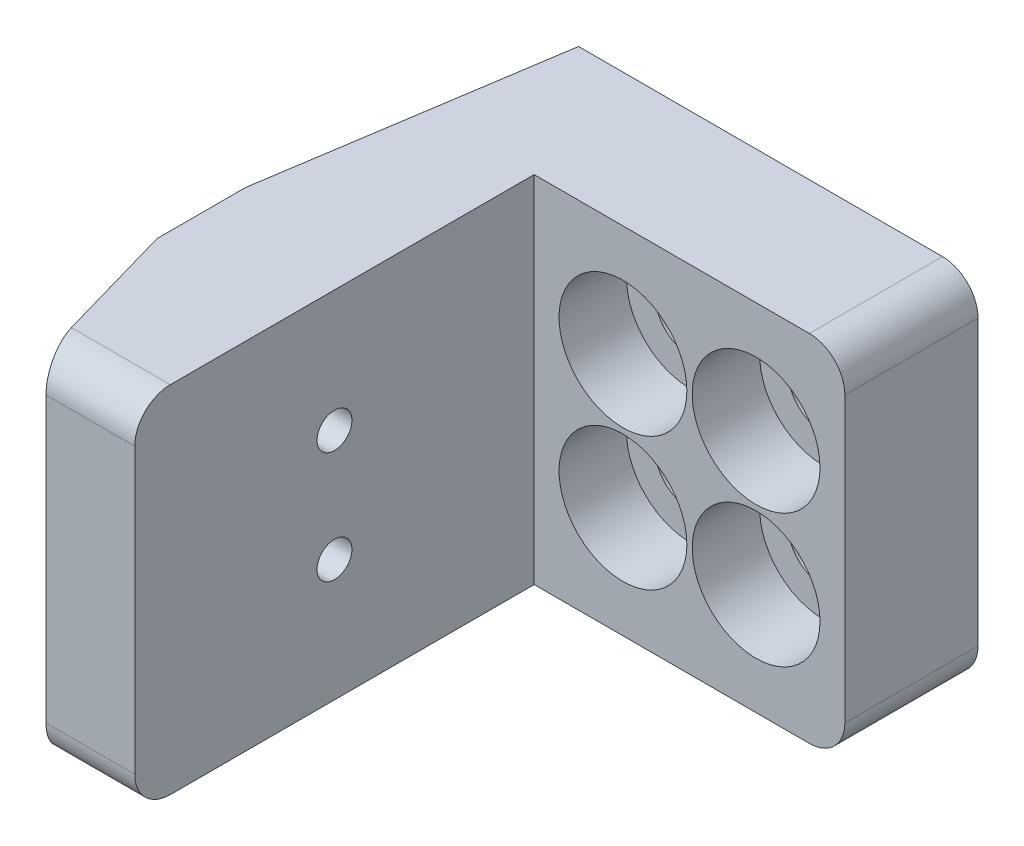
from build123d import *

# Parameters (mm, degrees)
BOSS_EXTRUDE1_DEPTH                             = 25.4
CBORE_FOR_10_SOCKET_HEAD_CAP_SCREW1_D           = 5.1054
CBORE_FOR_10_SOCKET_HEAD_CAP_SCREW1_CBORE_D     = 9.144
CBORE_FOR_10_SOCKET_HEAD_CAP_SCREW1_CBORE_DEPTH = 4.826
M3X0_5_TAPPED_HOLE1_D                           = 2.5
FILLET1_R                                       = 2.54


with BuildPart() as part:
    # Sketch1 → Boss-Extrude1 (new body)
    with BuildSketch(Plane(origin=(0, 0, 0), x_dir=(1, 0, 0), z_dir=(0, 1, 0))):
        Polygon((0, 0), (22.225, 0), (22.225, 9.525), (-6.35, 9.525), (-9.525, -11.1125), (-9.525, -17.4625), (-6.35, -28.575), (0, -28.575), align=None)
    extrude(amount=BOSS_EXTRUDE1_DEPTH)

    # CBORE for #10 Socket Head Cap Screw1 (through all)
    with Locations(Plane.XY):
        with Locations((6.35, 17.4625), (15.875, 7.9375), (6.35, 7.9375), (15.875, 17.4625)):
            CounterBoreHole(CBORE_FOR_10_SOCKET_HEAD_CAP_SCREW1_D / 2, CBORE_FOR_10_SOCKET_HEAD_CAP_SCREW1_CBORE_D / 2, CBORE_FOR_10_SOCKET_HEAD_CAP_SCREW1_CBORE_DEPTH)

    # M3x0.5 Tapped Hole1 (through all)
    with Locations(Plane(origin=(0, 0, 0), x_dir=(0, 0, -1), z_dir=(1, 0, 0))):
        with Locations((-14.2875, 16.7), (-14.2875, 8.7)):
            Hole(M3X0_5_TAPPED_HOLE1_D / 2)

    # Fillet1
    fillet1_edges = [part.edges().sort_by_distance(p)[0] for p in [
        (22.225, 0, -4.7625),
        (22.225, 25.4, -4.7625),
        (-3.175, 25.4, 28.575),
        (-3.175, 0, 28.575),
    ]]
    fillet(fillet1_edges, radius=FILLET1_R)


solid = part.part
